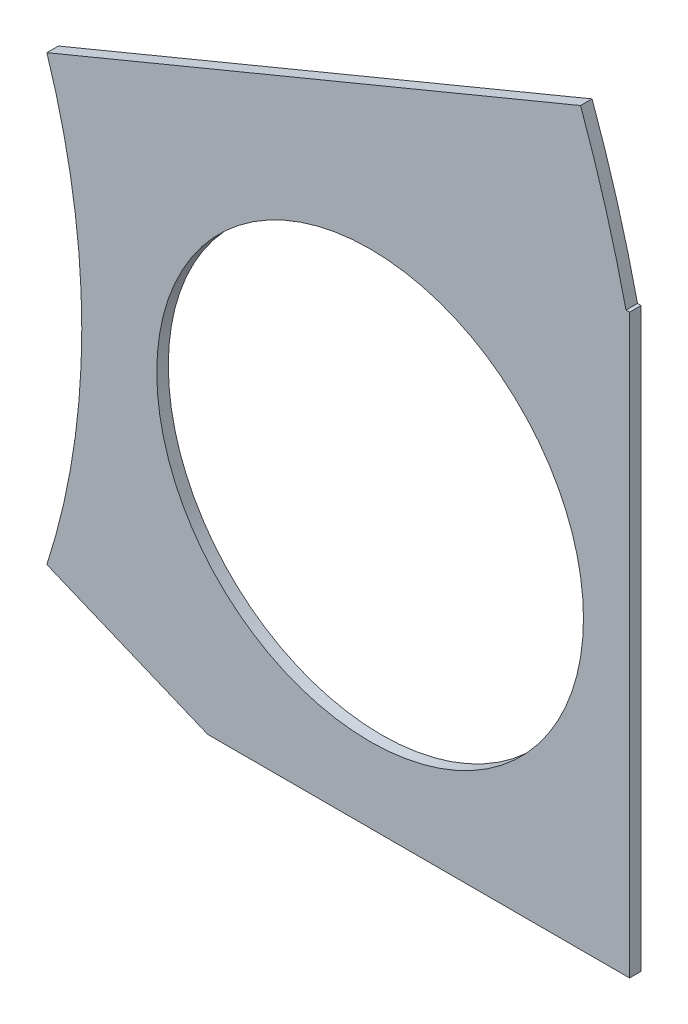
from build123d import *

# Parameters (mm, degrees)
BOSS_EXTRUDE1_DEPTH = 0.254
SKETCH2_R           = 4.699
CUT_EXTRUDE1_DEPTH  = 1.254
SKETCH3_W           = 2.54
SKETCH3_H           = 0.635
CUT_EXTRUDE2_DEPTH  = 1.254
SKETCH5_OUTSIDE_W   = 121.447
SKETCH5_OUTSIDE_H   = 109.618
CUT_EXTRUDE5_DEPTH  = 1.254


with BuildPart() as part:
    # Sketch1 → Boss-Extrude1 (new body)
    with BuildSketch(Plane.XY):
        with BuildLine():
            Line((67.21146711, 76.191723231), (8.696654013, 17.676910134))
            Line((8.696654013, 17.676910134), (7.228954972, 14.133571205))
            ThreePointArc((7.228954972, 14.133571205), (14.666587579, 6.075099489), (15.105587123, -4.88230096))
            Line((15.105587123, -4.88230096), (18.648926052, -6.35))
            Line((18.648926052, -6.35), (101.401368334, -6.35))
            ThreePointArc((101.401368334, -6.35), (93.866160503, 38.880636728), (67.21146711, 76.191723231))
        make_face()
        with BuildLine():
            Line((88.672924278, 6.35), (27.86051193, 6.35))
            ThreePointArc((27.86051193, 6.35), (26.399857642, 10.93517908), (24.190484974, 15.210228852))
            Line((24.190484974, 15.210228852), (67.191354125, 58.211098004))
            ThreePointArc((67.191354125, 58.211098004), (82.13289044, 34.020557137), (88.672924278, 6.35))
        make_face(mode=Mode.SUBTRACT)
    extrude(amount=BOSS_EXTRUDE1_DEPTH)

    # Sketch2 → Cut-Extrude1 (cut, through all)
    with BuildSketch(Plane.XY.offset(0.254)):
        with Locations((22.225, 0)):
            Circle(SKETCH2_R)
        with Locations((36.195, 0)):
            Circle(SKETCH2_R)
        with Locations((61.722, 0)):
            Circle(SKETCH2_R)
        with Locations((75.692, 0)):
            Circle(SKETCH2_R)
        with Locations((95.25, 0)):
            Circle(SKETCH2_R)
        with Locations((15.715448212, 15.715448212)):
            Circle(SKETCH2_R)
        with Locations((25.593729945, 25.593729945)):
            Circle(SKETCH2_R)
        with Locations((43.644044748, 43.644044748)):
            Circle(SKETCH2_R)
        with Locations((53.522326482, 53.522326482)):
            Circle(SKETCH2_R)
        with Locations((92.004434954, 24.652514046)):
            Circle(SKETCH2_R)
        with Locations((82.48891971, 47.625)):
            Circle(SKETCH2_R)
        with Locations((67.351920908, 67.351920908)):
            Circle(SKETCH2_R)
    extrude(amount=-CUT_EXTRUDE1_DEPTH, mode=Mode.SUBTRACT)

    # Sketch3 → Cut-Extrude2 (cut, through all)
    with BuildSketch(Plane.XY.offset(0.254)):
        Polygon((15.266435406, 24.246691527), (17.06248663, 26.042742751), (17.511499436, 25.593729945), (15.715448212, 23.797678721), align=None)
        Polygon((44.991083167, 53.971339288), (43.195031942, 52.175288063), (43.644044748, 51.726275257), (45.440095973, 53.522326482), align=None)
        with Locations((29.21, -6.0325)):
            Rectangle(SKETCH3_W, SKETCH3_H)
        with Locations((68.707, -6.0325)):
            Rectangle(SKETCH3_W, SKETCH3_H)
        Polygon((29.230733674, 38.210989795), (31.026784898, 40.007041019), (31.475797704, 39.558028213), (29.67974648, 37.761976989), align=None)
        Polygon((56.845021246, 65.825277367), (55.048970022, 64.029226143), (55.497982828, 63.580213337), (57.294034052, 65.376264561), align=None)
        with Locations((48.9585, -6.0325)):
            Rectangle(SKETCH3_W, SKETCH3_H)
        with Locations((85.471, -6.0325)):
            Rectangle(SKETCH3_W, SKETCH3_H)
        Polygon((99.935462164, 14.437711971), (100.266998693, 11.919442024), (101.526133667, 12.085210288), (101.194597138, 14.603480236), align=None)
        Polygon((93.765504959, 37.464305742), (94.938831965, 37.950313702), (93.966816047, 40.296967714), (92.793489041, 39.810959755), align=None)
        Polygon((79.327792988, 62.471156422), (80.874047017, 60.456038938), (81.88160576, 61.229165953), (80.33535173, 63.244283437), align=None)
        Polygon((13.593916116, 7.005422516), (14.565932035, 4.658768503), (15.739259041, 5.144776462), (14.767243123, 7.491430475), align=None)
    extrude(amount=-CUT_EXTRUDE2_DEPTH, mode=Mode.SUBTRACT)

    # Sketch5 outside → Cut-Extrude5 (cut, through all)
    with BuildSketch(Plane.XY.offset(0.254)):
        with Locations((54.4145, 34.921)):
            Rectangle(SKETCH5_OUTSIDE_W, SKETCH5_OUTSIDE_H)
        Polygon((11.513421912, 3.394377411), (27.94, 10.198488838), (27.94, -7.62), (11.513421912, -7.62), align=None, mode=Mode.SUBTRACT)
    extrude(amount=-CUT_EXTRUDE5_DEPTH, mode=Mode.SUBTRACT)


solid = part.part
